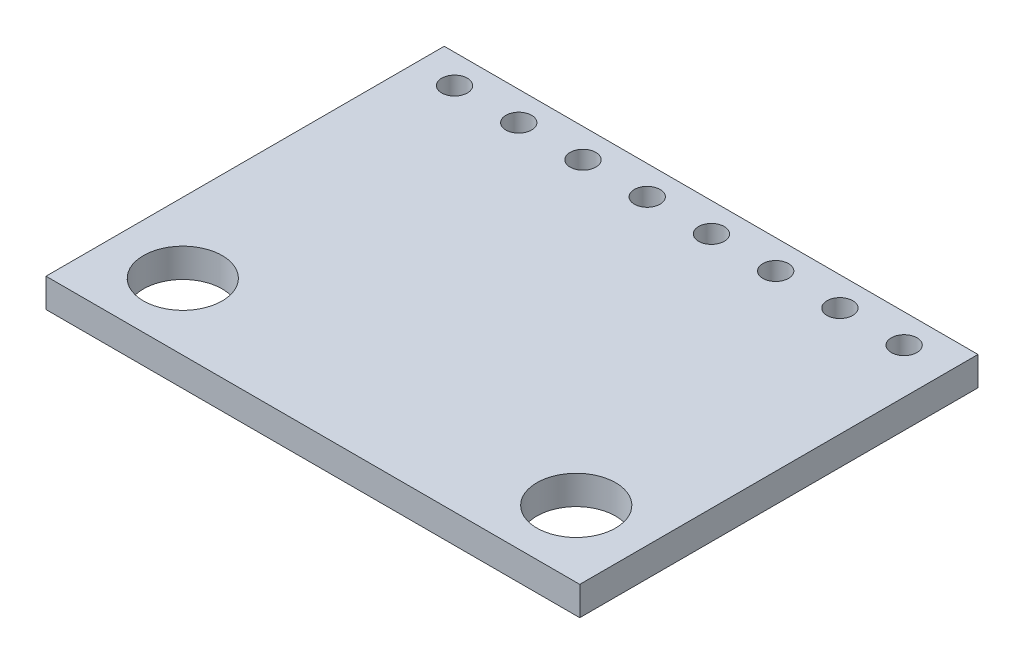
from build123d import *

# Parameters (mm, degrees)
SKETCH1_W           = 21.1074
SKETCH1_H           = 15.748
SKETCH1_R           = 1.55575
SKETCH1_R_2         = 0.508
BOSS_EXTRUDE1_DEPTH = 0.5715


with BuildPart() as part:
    # Sketch1 → Boss-Extrude1 (new body, symmetric)
    with BuildSketch(Plane(origin=(0, 0, 0), x_dir=(1, 0, 0), z_dir=(0, 1, 0))):
        Rectangle(SKETCH1_W, SKETCH1_H)
        with Locations((-7.77875, -5.23875)):
            Circle(SKETCH1_R, mode=Mode.SUBTRACT)
        with Locations((7.77875, -5.23875)):
            Circle(SKETCH1_R, mode=Mode.SUBTRACT)
        with Locations((-9.0043, 6.731)):
            Circle(SKETCH1_R_2, mode=Mode.SUBTRACT)
        with Locations((-6.4643, 6.731)):
            Circle(SKETCH1_R_2, mode=Mode.SUBTRACT)
        with Locations((-3.9243, 6.731)):
            Circle(SKETCH1_R_2, mode=Mode.SUBTRACT)
        with Locations((-1.3843, 6.731)):
            Circle(SKETCH1_R_2, mode=Mode.SUBTRACT)
        with Locations((1.1557, 6.731)):
            Circle(SKETCH1_R_2, mode=Mode.SUBTRACT)
        with Locations((3.6957, 6.731)):
            Circle(SKETCH1_R_2, mode=Mode.SUBTRACT)
        with Locations((6.2357, 6.731)):
            Circle(SKETCH1_R_2, mode=Mode.SUBTRACT)
        with Locations((8.7757, 6.731)):
            Circle(SKETCH1_R_2, mode=Mode.SUBTRACT)
    extrude(amount=BOSS_EXTRUDE1_DEPTH, both=True)


solid = part.part
